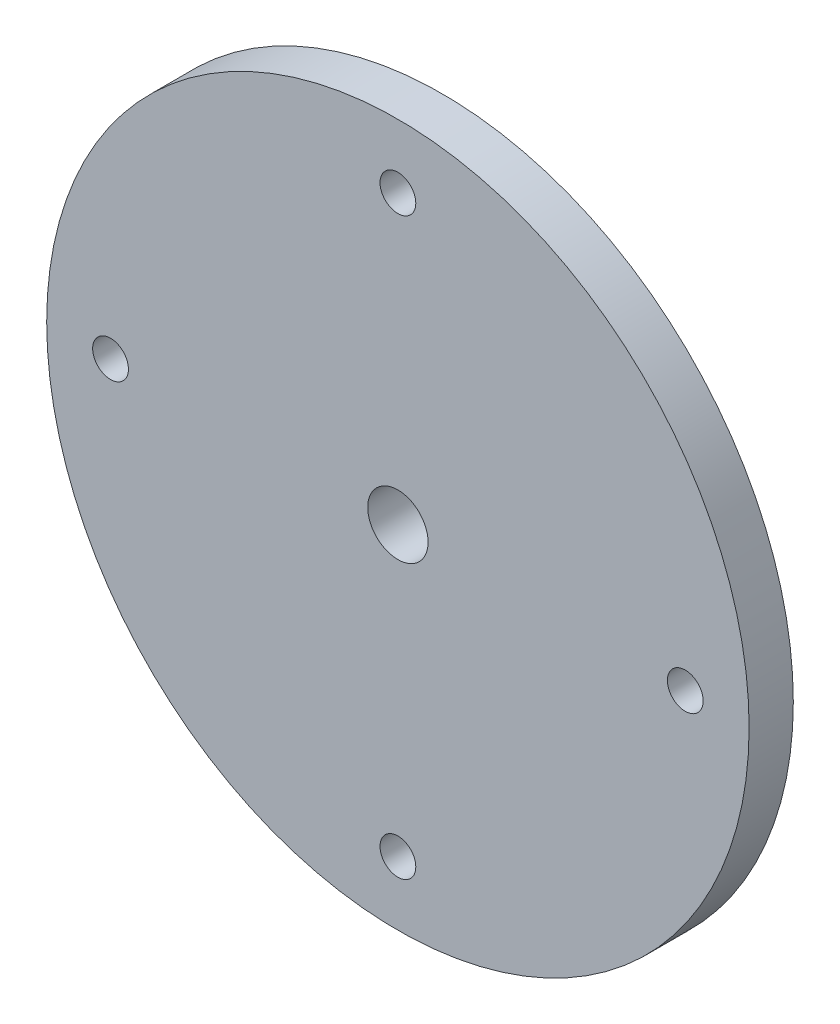
from build123d import *

# Parameters (mm, degrees)
SKETCH1_R           = 34.925
SKETCH1_R_2         = 3
SKETCH1_R_3         = 1.778
BOSS_EXTRUDE1_DEPTH = 4.3942


with BuildPart() as part:
    # Sketch1 → Boss-Extrude1 (new body)
    with BuildSketch(Plane.XY):
        Circle(SKETCH1_R)
        Circle(SKETCH1_R_2, mode=Mode.SUBTRACT)
        with Locations((0, 28.575)):
            Circle(SKETCH1_R_3, mode=Mode.SUBTRACT)
        with Locations((28.575, 0)):
            Circle(SKETCH1_R_3, mode=Mode.SUBTRACT)
        with Locations((0, -28.575)):
            Circle(SKETCH1_R_3, mode=Mode.SUBTRACT)
        with Locations((-28.575, 0)):
            Circle(SKETCH1_R_3, mode=Mode.SUBTRACT)
    extrude(amount=BOSS_EXTRUDE1_DEPTH)


solid = part.part
